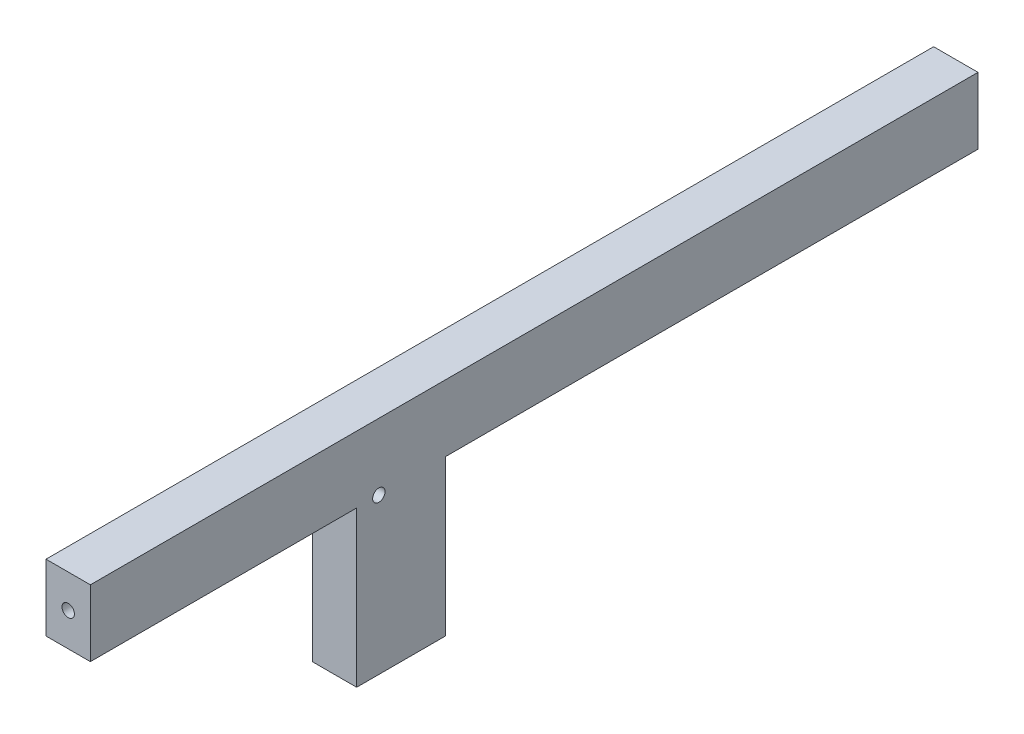
from build123d import *

# Parameters (mm, degrees)
BOSS_EXTRUDE1_DEPTH       = 3.175
SKETCH2_W                 = 1.5875
SKETCH2_H                 = 3.175
CUT_EXTRUDE1_DEPTH        = 3.175
F_2_56_TAPPED_HOLE1_D     = 1.778
F_2_56_TAPPED_HOLE1_DEPTH = 5.588
F_2_56_TAPPED_HOLE1_TIP   = 0.53416509
F_2_56_TAPPED_HOLE2_D     = 1.778
F_2_56_TAPPED_HOLE2_DEPTH = 10.668
F_2_56_TAPPED_HOLE2_TIP   = 0.53416509
F_2_56_TAPPED_HOLE3_D     = 1.778
F_2_56_TAPPED_HOLE3_DEPTH = 10.668
F_2_56_TAPPED_HOLE3_TIP   = 0.53416509


with BuildPart() as part:
    # Sketch1 → Boss-Extrude1 (new body, symmetric)
    with BuildSketch(Plane(origin=(0, 0, 0), x_dir=(0, 0, -1), z_dir=(1, 0, 0))):
        Polygon((-6.35, -6.892849115), (-44.45, -6.892849115), (-44.45, 2.632150885), (82.55, 2.632150885), (82.55, -6.892849115), (6.35, -6.892849115), (6.35, -29.117849115), (-6.35, -29.117849115), align=None)
    extrude(amount=BOSS_EXTRUDE1_DEPTH, both=True)

    # Sketch2 → Cut-Extrude1 (cut)
    with BuildSketch(Plane(origin=(0, 0, -6.35), x_dir=(-1, 0, 0), z_dir=(0, 0, -1))):
        with Locations((-0.79375, -11.072771518)):
            Rectangle(SKETCH2_W, SKETCH2_H)
        with Locations((-0.79375, -23.772771518)):
            Rectangle(SKETCH2_W, SKETCH2_H)
    extrude(amount=-CUT_EXTRUDE1_DEPTH, mode=Mode.SUBTRACT)

    # #2-56 Tapped Hole1
    with Locations(Plane(origin=(3.175, 0, 0), x_dir=(0, 0, -1), z_dir=(1, 0, 0))):
        with Locations((-3.175, -6.892849115)):
            Hole(F_2_56_TAPPED_HOLE1_D / 2, depth=F_2_56_TAPPED_HOLE1_DEPTH)
            with Locations((0, 0, -(F_2_56_TAPPED_HOLE1_DEPTH + F_2_56_TAPPED_HOLE1_TIP / 2))):  # 118° drill point
                Cone(0, F_2_56_TAPPED_HOLE1_D / 2, F_2_56_TAPPED_HOLE1_TIP, mode=Mode.SUBTRACT)

    # #2-56 Tapped Hole2
    with Locations(Plane.XY.offset(44.45)):
        with Locations((0, -2.130349115)):
            Hole(F_2_56_TAPPED_HOLE2_D / 2, depth=F_2_56_TAPPED_HOLE2_DEPTH)
            with Locations((0, 0, -(F_2_56_TAPPED_HOLE2_DEPTH + F_2_56_TAPPED_HOLE2_TIP / 2))):  # 118° drill point
                Cone(0, F_2_56_TAPPED_HOLE2_D / 2, F_2_56_TAPPED_HOLE2_TIP, mode=Mode.SUBTRACT)

    # #2-56 Tapped Hole3
    with Locations(Plane(origin=(0, 0, -82.55), x_dir=(-1, 0, 0), z_dir=(0, 0, -1))):
        with Locations((0, -2.130349115)):
            Hole(F_2_56_TAPPED_HOLE3_D / 2, depth=F_2_56_TAPPED_HOLE3_DEPTH)
            with Locations((0, 0, -(F_2_56_TAPPED_HOLE3_DEPTH + F_2_56_TAPPED_HOLE3_TIP / 2))):  # 118° drill point
                Cone(0, F_2_56_TAPPED_HOLE3_D / 2, F_2_56_TAPPED_HOLE3_TIP, mode=Mode.SUBTRACT)


solid = part.part
